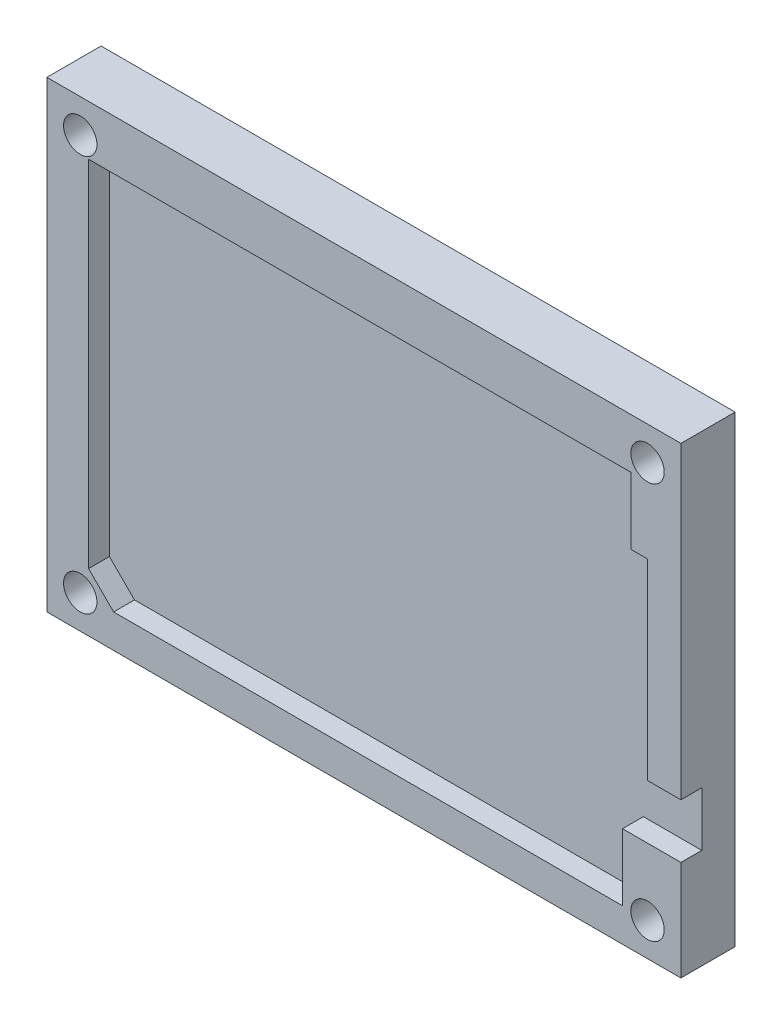
from build123d import *

# Parameters (mm, degrees)
SKETCH1_W                 = 76
SKETCH1_H                 = 55.5
BOSS_EXTRUDE1_DEPTH       = 4
BOSS_EXTRUDE2_DEPTH       = 2.5
F_4_0MM_DOWEL_HOLE1_D     = 4
F_4_0MM_DOWEL_HOLE1_DEPTH = 6.5


with BuildPart() as part:
    # Sketch1 → Boss-Extrude1 (new body)
    with BuildSketch(Plane.XY):
        with Locations((-0.361045131, -5.590855107)):
            Rectangle(SKETCH1_W, SKETCH1_H)
    extrude(amount=BOSS_EXTRUDE1_DEPTH)

    # Sketch2 → Boss-Extrude2 (add)
    with BuildSketch(Plane.XY.offset(4)):
        Polygon((-38.361045131, 22.159144893), (37.638954869, 22.159144893), (37.638954869, 16.159144893), (37.638954869, 8.159144893), (37.638954869, -14.840855107), (33.638954869, -14.840855107), (33.638954869, 8.159144893), (31.638954869, 8.159144893), (31.638954869, 16.159144893), (-33.361045131, 16.159144893), (-33.361045131, -26.340855107), (-30.361045131, -29.340855107), (30.638954869, -29.340855107), (30.638954869, -21.340855107), (37.638954869, -21.340855107), (37.638954869, -29.340855107), (37.638954869, -33.340855107), (-33.361045131, -33.340855107), (-38.361045131, -33.340855107), (-38.361045131, 16.159144893), align=None)
    extrude(amount=BOSS_EXTRUDE2_DEPTH)

    # Ø4.0mm Dowel Hole1
    with Locations(Plane.XY.offset(6.5)):
        with Locations((-34.361045131, 18.159144893), (33.638954869, 18.159144893), (33.638954869, -29.340855107), (-34.361045131, -29.340855107)):
            Hole(F_4_0MM_DOWEL_HOLE1_D / 2, depth=F_4_0MM_DOWEL_HOLE1_DEPTH)


solid = part.part
